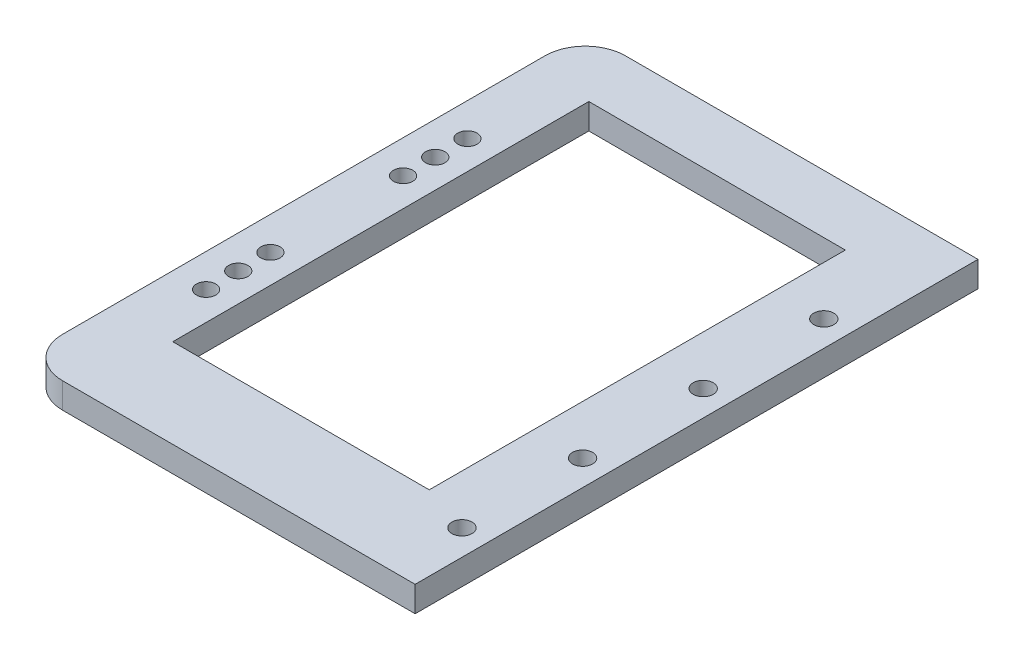
from build123d import *

# Parameters (mm, degrees)
SKETCH1_W                 = 97.7
SKETCH1_H                 = 140
BOSS_EXTRUDE1_DEPTH       = 6.35
FILLET1_R                 = 10
CUT_EXTRUDE1_DEPTH        = 6.35
SKETCH5_R                 = 2.4
CUT_EXTRUDE2_DEPTH        = 6.35
F_5_0MM_DOWEL_HOLE1_D     = 5
F_5_0MM_DOWEL_HOLE1_DEPTH = 10
F_5_0MM_DOWEL_HOLE1_TIP   = 1.502151548


with BuildPart() as part:
    # Sketch1 → Boss-Extrude1 (new body)
    with BuildSketch(Plane(origin=(0, 0, 0), x_dir=(1, 0, 0), z_dir=(0, 1, 0))):
        with Locations((3.993769968, 7.891373802)):
            Rectangle(SKETCH1_W, SKETCH1_H)
    extrude(amount=BOSS_EXTRUDE1_DEPTH)

    # Fillet1
    fillet1_edges = [part.edges().sort_by_distance(p)[0] for p in [
        (-44.856230032, 3.175, -77.891373802),
        (-44.856230032, 3.175, 62.108626198),
    ]]
    fillet(fillet1_edges, radius=FILLET1_R)

    # Sketch3 → Cut-Extrude1 (cut)
    with BuildSketch(Plane(origin=(0, 6.35, 0), x_dir=(1, 0, 0), z_dir=(0, 1, 0))):
        Polygon((-29.556230032, 63.491373802), (-29.556230032, -40), (34.243769968, -40), (34.343769968, 63.391373802), align=None)
    extrude(amount=-CUT_EXTRUDE1_DEPTH, mode=Mode.SUBTRACT)

    # Sketch5 → Cut-Extrude2 (cut)
    with BuildSketch(Plane(origin=(0, 6.35, 0), x_dir=(1, 0, 0), z_dir=(0, 1, 0))):
        with Locations((-36.656230032, 40.391373802)):
            Circle(SKETCH5_R)
        with Locations((-36.656230032, 24.391373802)):
            Circle(SKETCH5_R)
        with Locations((-36.656230032, -8.608626198)):
            Circle(SKETCH5_R)
        with Locations((-36.656230032, -24.608626198)):
            Circle(SKETCH5_R)
        with Locations((-36.656230032, -16.608626198)):
            Circle(SKETCH5_R)
        with Locations((-36.656230032, 32.391373802)):
            Circle(SKETCH5_R)
    extrude(amount=-CUT_EXTRUDE2_DEPTH, mode=Mode.SUBTRACT)

    # Ø5.0mm Dowel Hole1
    with Locations(Plane(origin=(0, 6.35, 0), x_dir=(1, 0, 0), z_dir=(0, 1, 0))):
        with Locations((46.493769968, 45.888131535), (46.493769968, 15.888131535), (46.493769968, -14.111868465), (46.493769968, -44.111868465)):
            Hole(F_5_0MM_DOWEL_HOLE1_D / 2, depth=F_5_0MM_DOWEL_HOLE1_DEPTH)
            with Locations((0, 0, -(F_5_0MM_DOWEL_HOLE1_DEPTH + F_5_0MM_DOWEL_HOLE1_TIP / 2))):  # 118° drill point
                Cone(0, F_5_0MM_DOWEL_HOLE1_D / 2, F_5_0MM_DOWEL_HOLE1_TIP, mode=Mode.SUBTRACT)


solid = part.part
